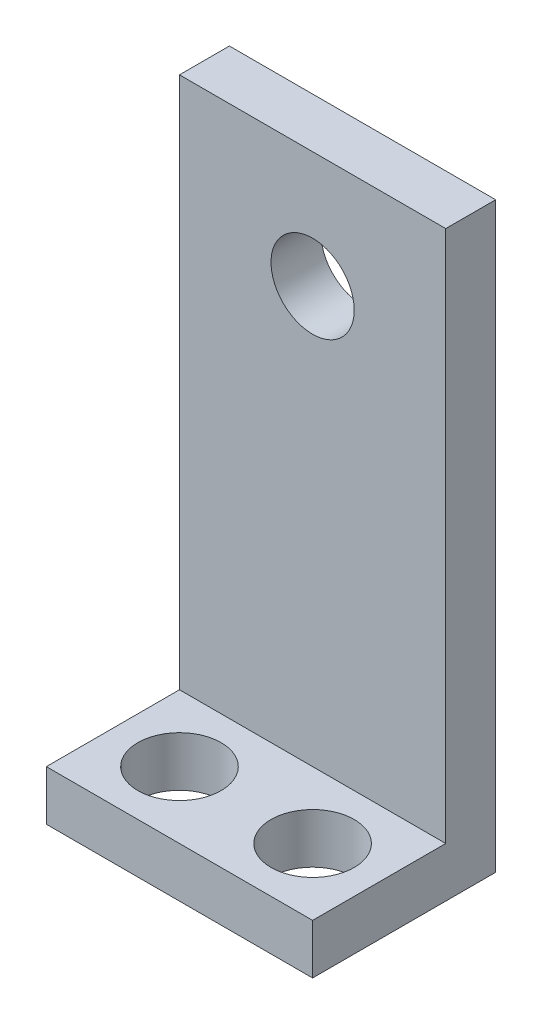
from build123d import *

# Parameters (mm, degrees)
SKETCH1_W           = 16
SKETCH1_H           = 3
BOSS_EXTRUDE1_DEPTH = 35
SKETCH1_3_W         = 16
SKETCH1_3_H         = 8
SKETCH1_3_R         = 2.5
BOSS_EXTRUDE2_DEPTH = 3
SKETCH2_R           = 2.5
CUT_EXTRUDE1_DEPTH  = 8


with BuildPart() as part:
    # Sketch1 → Boss-Extrude1 (new body)
    with BuildSketch(Plane(origin=(0, 0, 0), x_dir=(1, 0, 0), z_dir=(0, 1, 0))):
        with Locations((0, 4)):
            Rectangle(SKETCH1_W, SKETCH1_H)
    extrude(amount=BOSS_EXTRUDE1_DEPTH)

    # Sketch1_3 → Boss-Extrude2 (add)
    with BuildSketch(Plane(origin=(0, 0, 0), x_dir=(1, 0, 0), z_dir=(0, 1, 0))):
        with Locations((0, -1.5)):
            Rectangle(SKETCH1_3_W, SKETCH1_3_H)
        with Locations((-4, -1.5)):
            Circle(SKETCH1_3_R, mode=Mode.SUBTRACT)
        with Locations((4, -1.5)):
            Circle(SKETCH1_3_R, mode=Mode.SUBTRACT)
    extrude(amount=BOSS_EXTRUDE2_DEPTH)

    # Sketch2 → Cut-Extrude1 (cut)
    with BuildSketch(Plane.XY.offset(-2.5)):
        with Locations((0, 28)):
            Circle(SKETCH2_R)
    extrude(amount=-CUT_EXTRUDE1_DEPTH, mode=Mode.SUBTRACT)


solid = part.part
